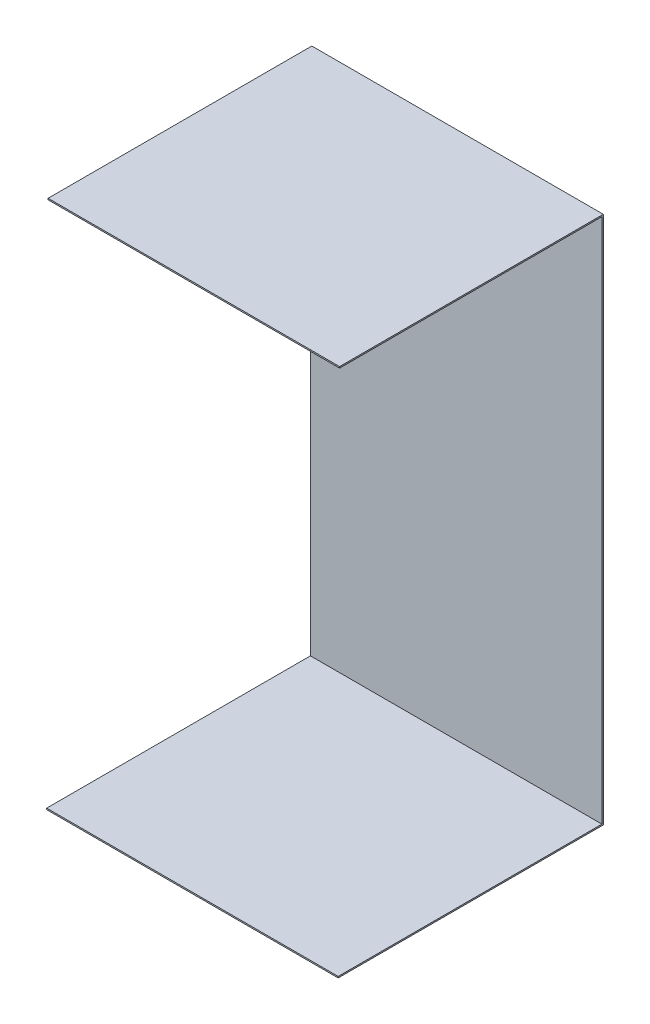
from build123d import *

# Parameters (mm, degrees)
SKETCH3_W           = 420
SKETCH3_H           = 760
BOSS_EXTRUDE1_DEPTH = 2
SKETCH7_W           = 380
SKETCH7_H           = 2
BOSS_EXTRUDE2_DEPTH = 420
SKETCH9_W           = 382
SKETCH9_H           = 2
BOSS_EXTRUDE3_DEPTH = 420


with BuildPart() as part:
    # Sketch3 → Boss-Extrude1 (new body)
    with BuildSketch(Plane.XY):
        with Locations((210, 380)):
            Rectangle(SKETCH3_W, SKETCH3_H)
    extrude(amount=BOSS_EXTRUDE1_DEPTH)

    # Sketch7 → Boss-Extrude2 (add)
    with BuildSketch(Plane(origin=(420, 760, 0), x_dir=(0, 0, 1), z_dir=(-1, 0, 0))):
        with Locations((190, 1)):
            Rectangle(SKETCH7_W, SKETCH7_H)
    extrude(amount=BOSS_EXTRUDE2_DEPTH)

    # Sketch9 → Boss-Extrude3 (add)
    with BuildSketch(Plane(origin=(420, 0, 2), x_dir=(0, 0, -1), z_dir=(1, 0, 0))):
        with Locations((-189, 1)):
            Rectangle(SKETCH9_W, SKETCH9_H)
    extrude(amount=-BOSS_EXTRUDE3_DEPTH)


solid = part.part
